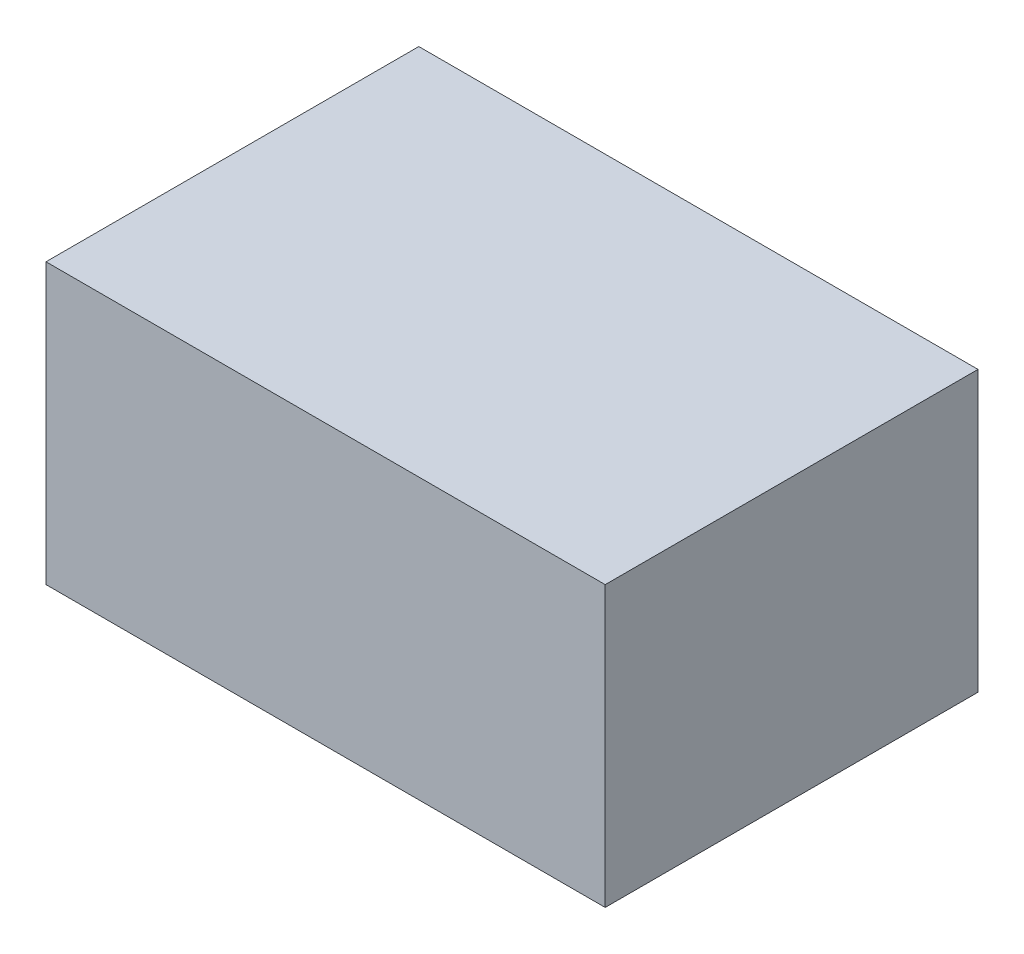
from build123d import *

# Parameters (mm, degrees)
SKETCH1_W           = 60
SKETCH1_H           = 40
BOSS_EXTRUDE1_DEPTH = 30


with BuildPart() as part:
    # Sketch1 → Boss-Extrude1 (new body)
    with BuildSketch(Plane(origin=(0, 0, 0), x_dir=(1, 0, 0), z_dir=(0, 1, 0))):
        with Locations((-10.323529412, 8.970588235)):
            Rectangle(SKETCH1_W, SKETCH1_H)
    extrude(amount=BOSS_EXTRUDE1_DEPTH)


solid = part.part
